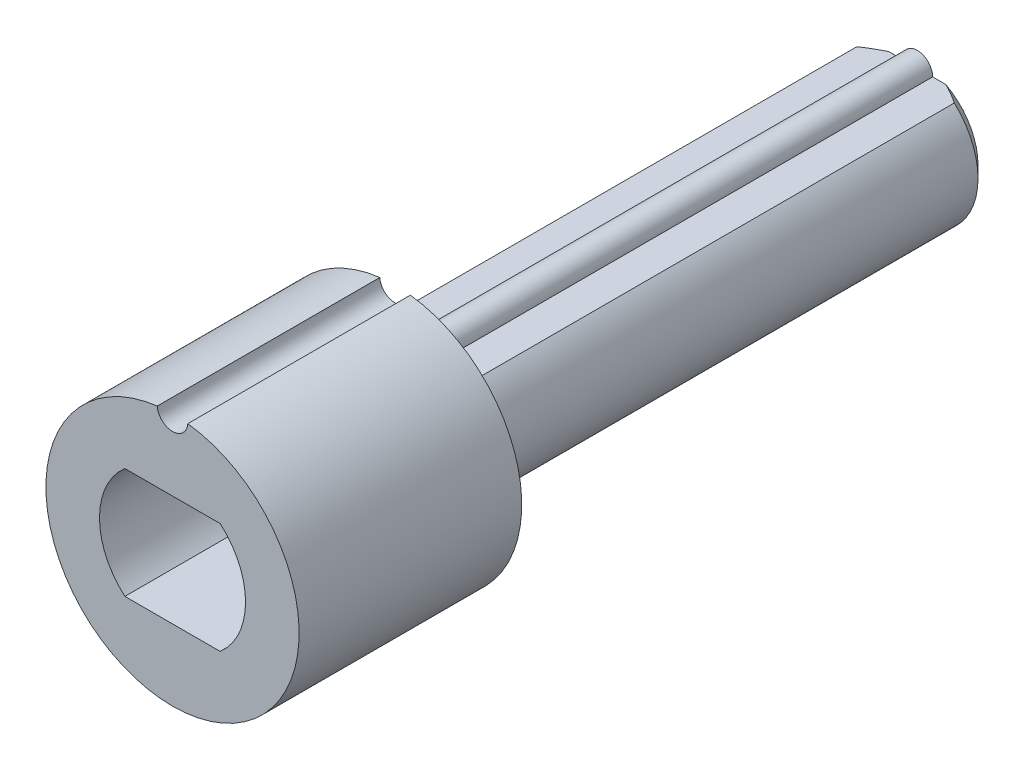
from build123d import *

# Parameters (mm, degrees)
BOSS_EXTRUDE1_DEPTH = 22.17
BOSS_EXTRUDE2_DEPTH = 9.45
CUT_EXTRUDE1_DEPTH  = 6.8
CHAMFER1_SIZE       = 0.5


with BuildPart() as part:
    # Sketch1 → Boss-Extrude1 (new body)
    with BuildSketch(Plane.XY):
        with BuildLine():
            Line((0.65, 2.275), (2.068816087, 2.275))
            ThreePointArc((2.068816087, 2.275), (3.075, 0), (2.068816087, -2.275))
            Line((2.068816087, -2.275), (-2.068816087, -2.275))
            ThreePointArc((-2.068816087, -2.275), (-3.075, 0), (-2.068816087, 2.275))
            Line((-2.068816087, 2.275), (-0.65, 2.275))
            ThreePointArc((-0.65, 2.275), (0, 2.925), (0.65, 2.275))
        make_face()
    extrude(amount=BOSS_EXTRUDE1_DEPTH)

    # Sketch2 → Boss-Extrude2 (add)
    with BuildSketch(Plane.XY.offset(22.17)):
        with BuildLine():
            ThreePointArc((-0.648810702, 5.335697674), (0, -5.375), (0.648810702, 5.335697674))
            ThreePointArc((0.648810702, 5.335697674), (0, 4.725), (-0.648810702, 5.335697674))
        make_face()
    extrude(amount=BOSS_EXTRUDE2_DEPTH)

    # Sketch3 → Cut-Extrude1 (cut)
    with BuildSketch(Plane.XY.offset(31.62)):
        with BuildLine():
            Line((-2.021756662, 2.35), (2.021756662, 2.35))
            ThreePointArc((2.021756662, 2.35), (3.1, 0), (2.021756662, -2.35))
            Line((2.021756662, -2.35), (-2.021756662, -2.35))
            ThreePointArc((-2.021756662, -2.35), (-3.1, 0), (-2.021756662, 2.35))
        make_face()
    extrude(amount=-CUT_EXTRUDE1_DEPTH, mode=Mode.SUBTRACT)

    # Chamfer1
    chamfer1_edges = [part.edges().sort_by_distance(p)[0] for p in [
        (3.075, 0, 0),
        (-3.075, 0, 0),
    ]]
    chamfer(chamfer1_edges, length=CHAMFER1_SIZE)


solid = part.part
